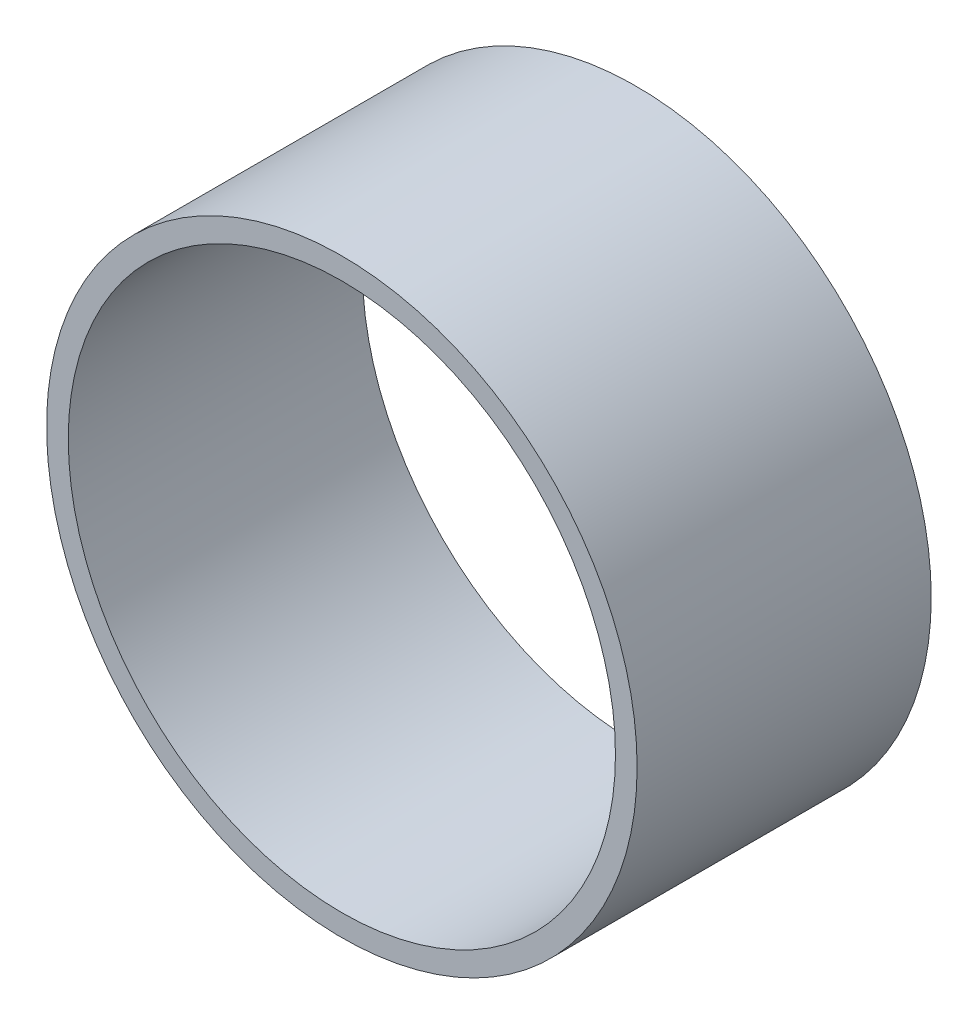
from build123d import *

# Parameters (mm, degrees)
SKETCH_1_R      = 38.15
SKETCH_1_R_2    = 35.35
EXTRUDE_1_DEPTH = 38


with BuildPart() as part:
    # ｽｹｯﾁ1 → ﾎﾞｽ - 押し出し1 (new body)
    with BuildSketch(Plane.XY):
        Circle(SKETCH_1_R)
        Circle(SKETCH_1_R_2, mode=Mode.SUBTRACT)
    extrude(amount=EXTRUDE_1_DEPTH)


solid = part.part
